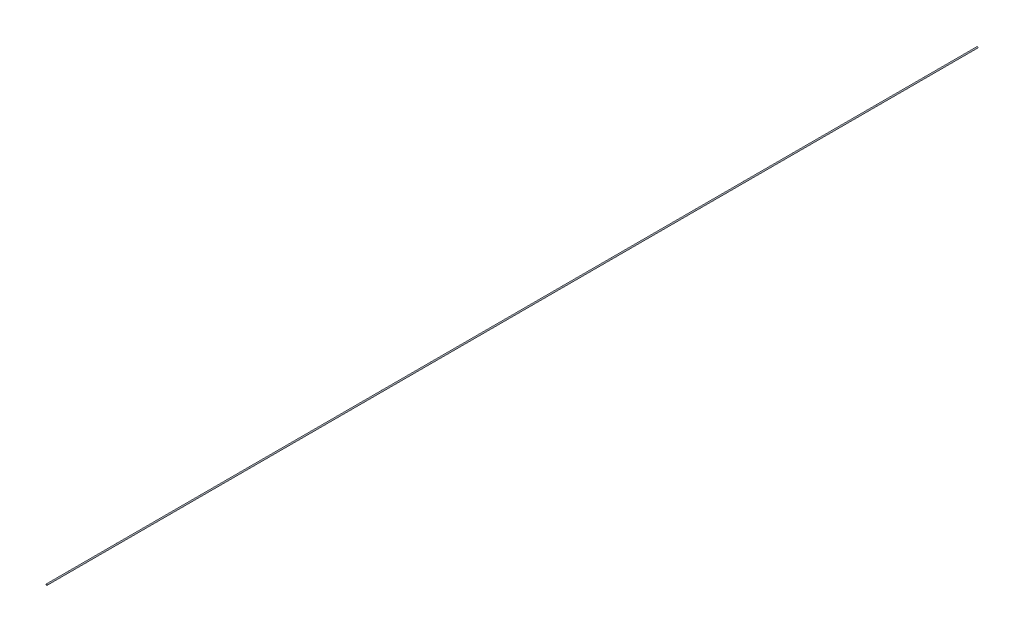
from build123d import *

# Parameters (mm, degrees)
SKETCH1_R           = 0.0625
BOSS_EXTRUDE1_DEPTH = 100


with BuildPart() as part:
    # Sketch1 → Boss-Extrude1 (new body)
    with BuildSketch(Plane.XY):
        Circle(SKETCH1_R)
    extrude(amount=BOSS_EXTRUDE1_DEPTH)


solid = part.part
